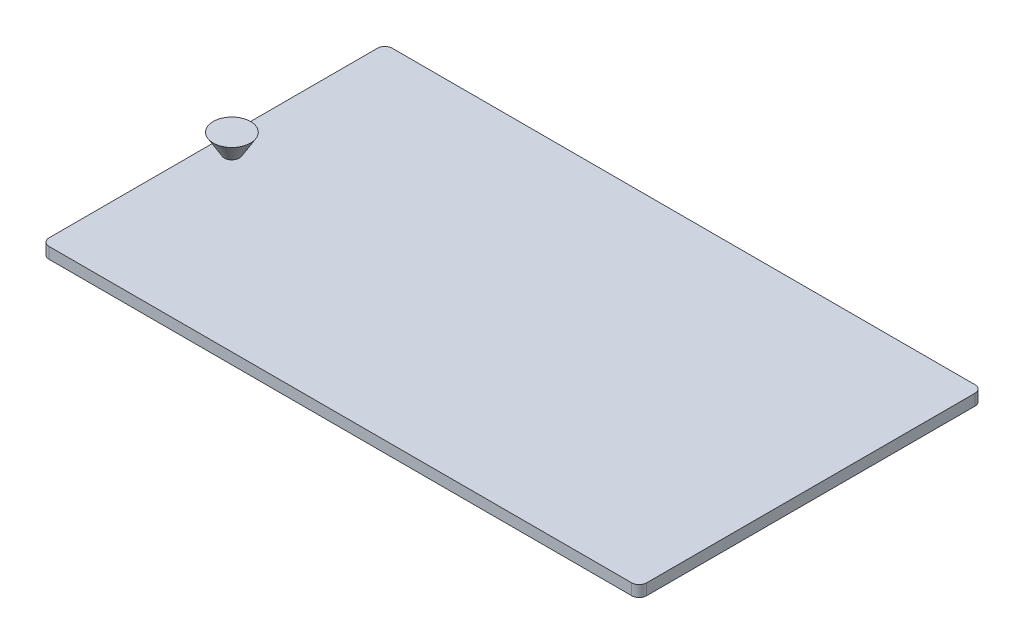
from build123d import *

# Parameters (mm, degrees)
BOSS_EXTRUDE3_DEPTH = 3
SKETCH3_R           = 5
SKETCH2_R           = 2


with BuildPart() as part:
    # Sketch1 → Boss-Extrude3 (new body)
    with BuildSketch(Plane(origin=(0, 0, 0), x_dir=(1, 0, 0), z_dir=(0, 1, 0))):
        with BuildLine():
            Line((-78, 45.95), (78, 45.95))
            ThreePointArc((78, 45.95), (79.414213562, 45.364213562), (80, 43.95))
            Line((80, 43.95), (80, -43.95))
            ThreePointArc((80, -43.95), (79.414213562, -45.364213562), (78, -45.95))
            Line((78, -45.95), (-78, -45.95))
            ThreePointArc((-78, -45.95), (-79.414213562, -45.364213562), (-80, -43.95))
            Line((-80, -43.95), (-80, 43.95))
            ThreePointArc((-80, 43.95), (-79.414213562, 45.364213562), (-78, 45.95))
        make_face()
    extrude(amount=BOSS_EXTRUDE3_DEPTH)

    # Sketch3 → Loft1 section 0
    with BuildSketch(Plane(origin=(0, 8, 0), x_dir=(1, 0, 0), z_dir=(0, 1, 0))):
        with Locations((-75, 0)):
            Circle(SKETCH3_R)
    # Sketch2 → Loft1 section 1
    with BuildSketch(Plane(origin=(0, 3, 0), x_dir=(1, 0, 0), z_dir=(0, 1, 0))):
        with Locations((-75, 0)):
            Circle(SKETCH2_R)
    loft()


solid = part.part
